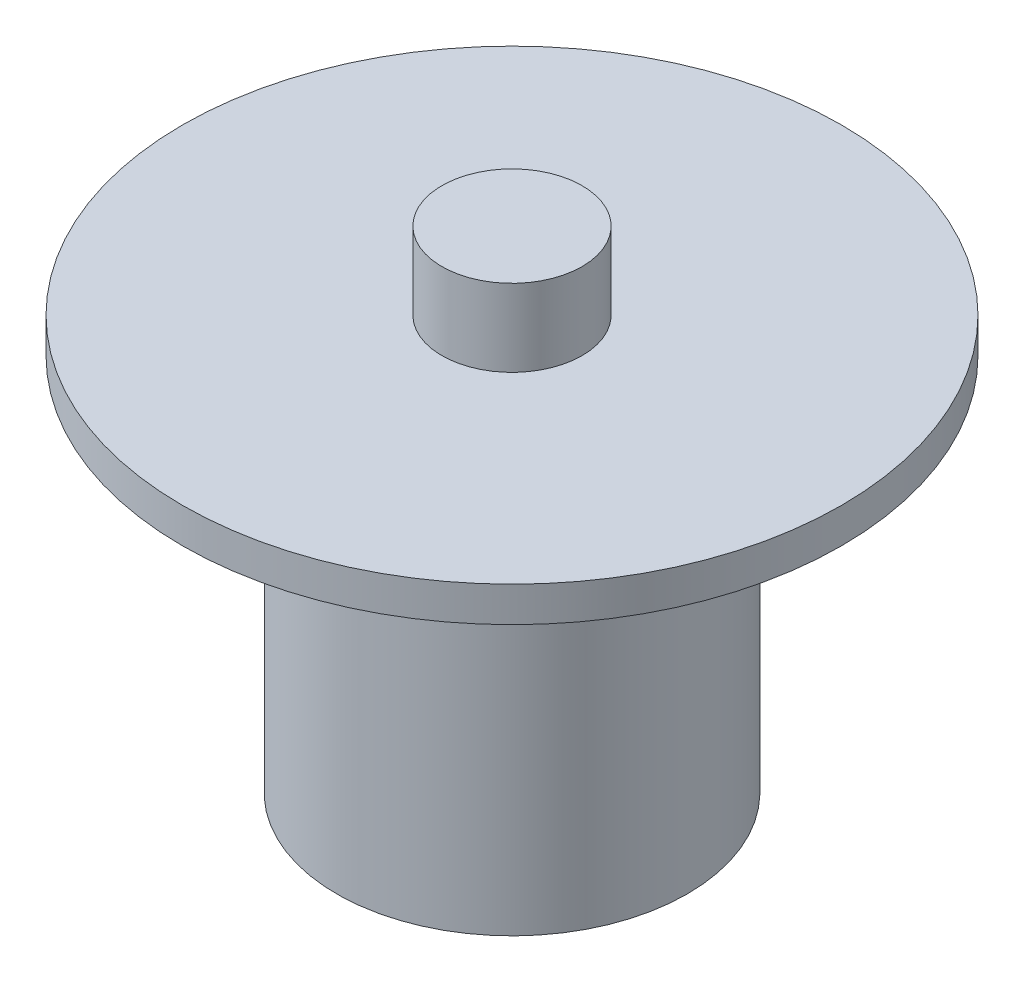
from build123d import *


with BuildPart() as part:
    # Sketch1 → Revolve1 (revolve)
    with BuildSketch(Plane.XY):
        Polygon((0, -8.75), (0, 8.75), (-2.5, 8.75), (-2.5, 6), (-11.75, 6), (-11.75, 4.75), (-6.25, 4.75), (-6.25, -8.75), align=None)
    revolve(axis=Axis((0, -8.75, 0), (0, 1, 0)))


solid = part.part
